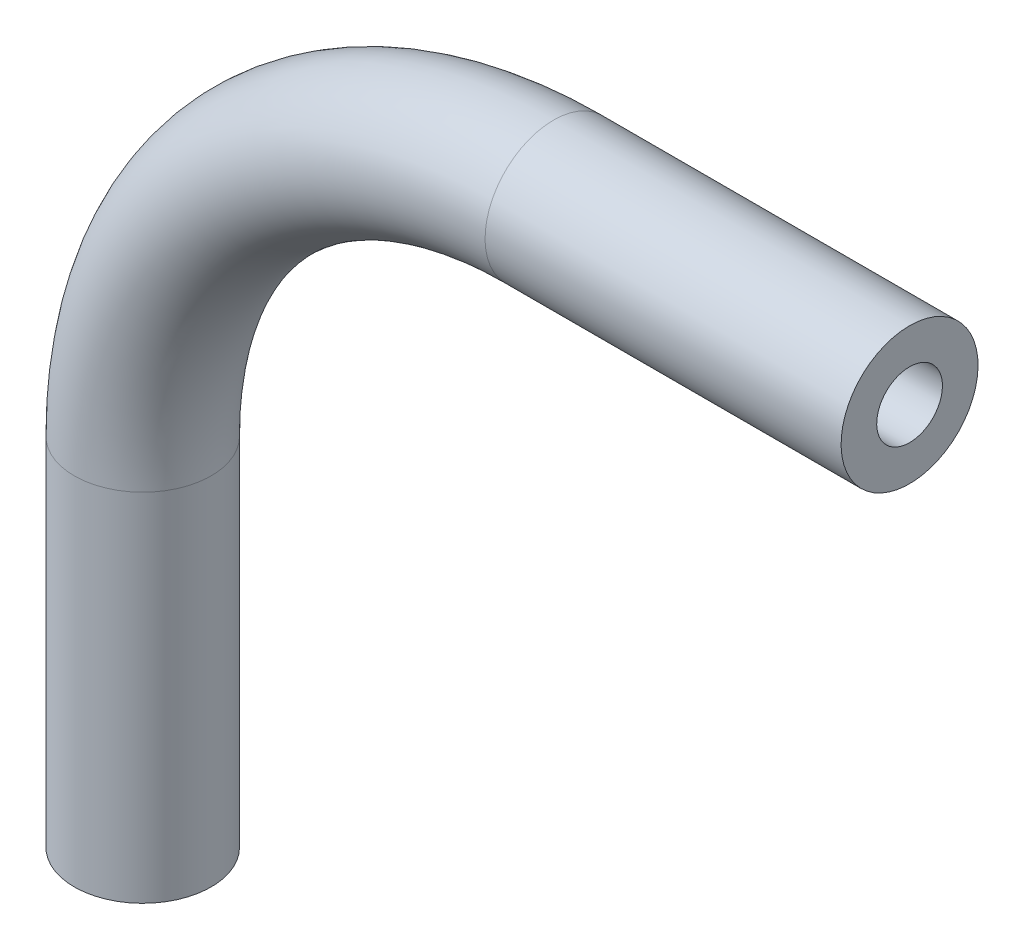
from build123d import *

# Parameters (mm, degrees)
SKETCH2_R   = 3.175
SKETCH2_R_2 = 1.524


with BuildPart() as part:
    # Sweep1: sweep along a path in Sketch1
    with BuildLine(Plane.XY) as sweep1_path:
        Line((0, -18.032317881), (0, -1.522317881))
        ThreePointArc((0, -1.522317881), (5.579615818, 11.948066301), (19.05, 17.527682119))
        Line((19.05, 17.527682119), (35.56, 17.527682119))
    # Sketch2 → Sweep1 (sweep)
    with BuildSketch(Plane(origin=(35.56, 17.527682119, 0), x_dir=(0, 0, -1), z_dir=(1, 0, 0))):
        Circle(SKETCH2_R)
        Circle(SKETCH2_R_2, mode=Mode.SUBTRACT)
    sweep(path=sweep1_path.line)


solid = part.part
